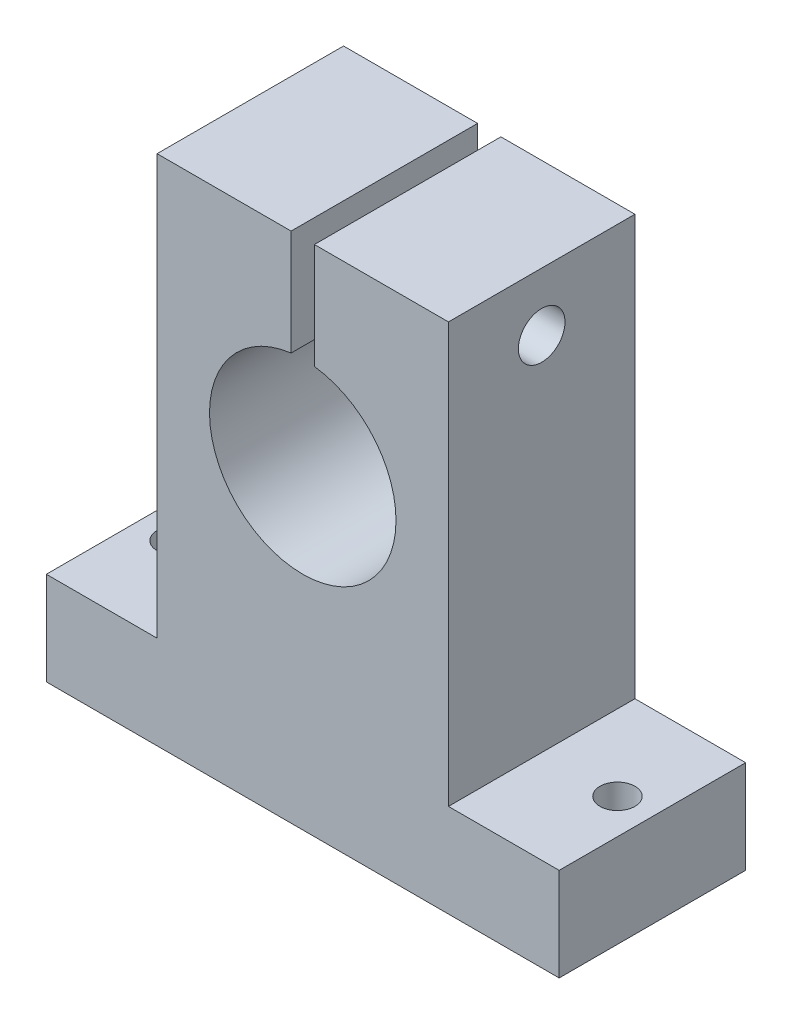
from build123d import *

# Parameters (mm, degrees)
SKETCH_1_R          = 8
EXTRUDE_1_DEPTH     = 16
SKETCH_2_W          = 2
SKETCH_2_H          = 16
CUT_EXTRUDE_1_DEPTH = 16
SKETCH_3_R          = 2
CUT_EXTRUDE_2_DEPTH = 39
SKETCH_4_R          = 1.5
CUT_EXTRUDE_3_DEPTH = 39


with BuildPart() as part:
    # 草图1 → 凸台-拉伸1 (new body)
    with BuildSketch(Plane.XY):
        Polygon((-24.921659643, 3.123294018), (19.078340357, 3.123294018), (19.078340357, 11.123294018), (9.578340357, 11.123294018), (9.578340357, 47.123294018), (-15.421659643, 47.123294018), (-15.421659643, 11.123294018), (-24.921659643, 11.123294018), align=None)
        with Locations((-2.921659643, 30.123294018)):
            Circle(SKETCH_1_R, mode=Mode.SUBTRACT)
    extrude(amount=EXTRUDE_1_DEPTH)

    # 草图2 → 切除-拉伸1 (cut)
    with BuildSketch(Plane(origin=(0, 47.123294018, 0), x_dir=(1, 0, 0), z_dir=(0, 1, 0))):
        with Locations((-2.921659643, -8)):
            Rectangle(SKETCH_2_W, SKETCH_2_H)
    extrude(amount=-CUT_EXTRUDE_1_DEPTH, mode=Mode.SUBTRACT)

    # 草图3 → 切除-拉伸2 (cut)
    with BuildSketch(Plane(origin=(9.578340357, 0, 0), x_dir=(0, 0, -1), z_dir=(1, 0, 0))):
        with Locations((-8, 42.123294018)):
            Circle(SKETCH_3_R)
    extrude(amount=-CUT_EXTRUDE_2_DEPTH, mode=Mode.SUBTRACT)

    # 草图4 → 切除-拉伸3 (cut)
    with BuildSketch(Plane.XZ.offset(-3.123294018)):
        with Locations((-21.921659643, 8)):
            Circle(SKETCH_4_R)
        with Locations((16.078340357, 8)):
            Circle(SKETCH_4_R)
    extrude(amount=-CUT_EXTRUDE_3_DEPTH, mode=Mode.SUBTRACT)


solid = part.part
